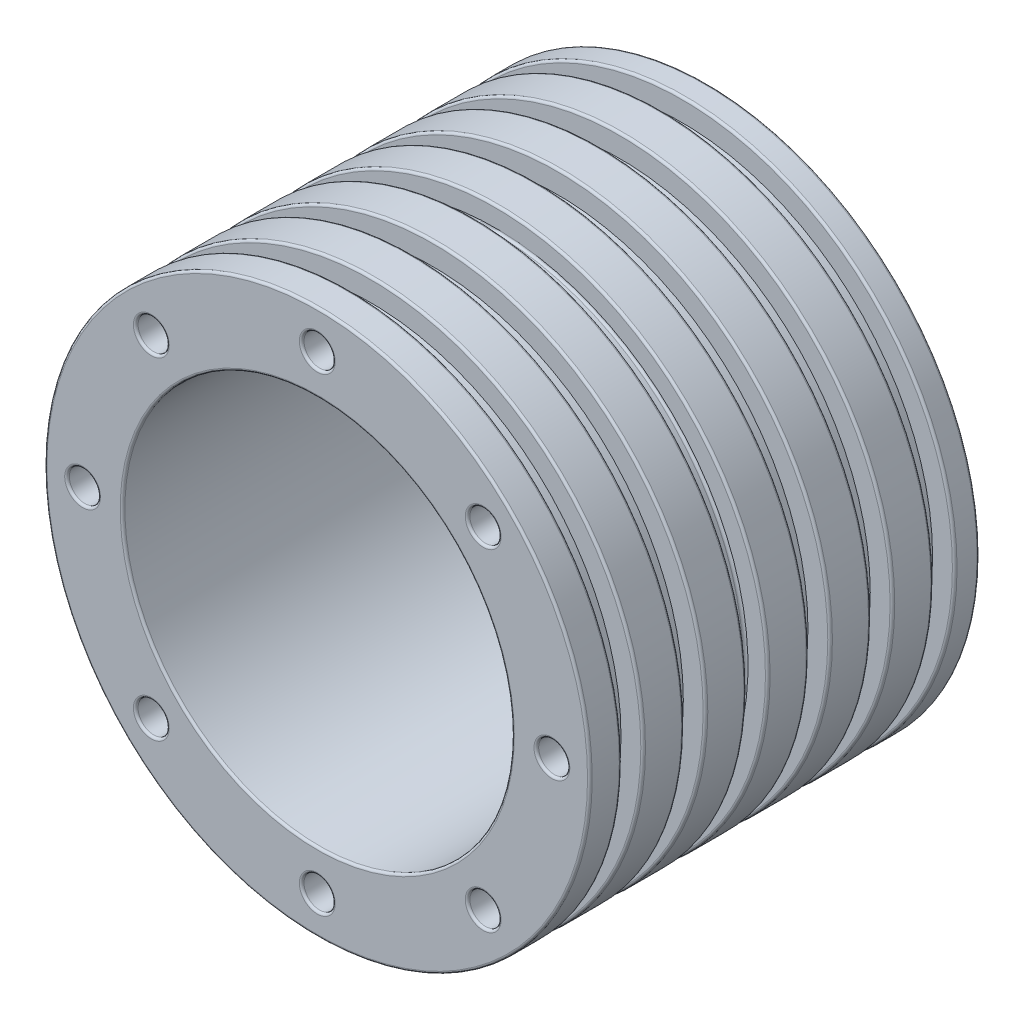
from build123d import *

# Parameters (mm, degrees)
SKETCH1_R           = 350
SKETCH1_R_2         = 250
BOSS_EXTRUDE1_DEPTH = 250
SKETCH2_W           = 27.603113623
SKETCH2_H           = 41.463524477
LPATTERN1_COUNT     = 6
LPATTERN1_PITCH     = 80
SKETCH3_R           = 20
CUT_EXTRUDE1_DEPTH  = 500
CIRPATTERN1_COUNT   = 8
FILLET1_R           = 3


with BuildPart() as part:
    # Sketch1 → Boss-Extrude1 (new, symmetric)
    with BuildSketch(Plane.XY):
        Circle(SKETCH1_R)
        Circle(SKETCH1_R_2, mode=Mode.SUBTRACT)
    extrude(amount=BOSS_EXTRUDE1_DEPTH, both=True)

    # Cut-Sweep1: sweep along a curve in space
    with BuildLine() as cut_sweep1_path:
        ThreePointArc((350, 0, 250), (247.487373415, 247.487373415, 250), (0, 350, 250))
        ThreePointArc((0, 350, 250), (-247.487373415, 247.487373415, 250), (-350, 0, 250))
        ThreePointArc((-350, 0, 250), (-247.487373415, -247.487373415, 250), (0, -350, 250))
        ThreePointArc((0, -350, 250), (247.487373415, -247.487373415, 250), (350, 0, 250))
    # Sketch2 → Cut-Sweep1 (sweep, cut)
    with BuildSketch(Plane(origin=(0, 0, 0), x_dir=(0, 0, -1), z_dir=(1, 0, 0))):
        with Locations((-195.42656015, 342.293613499)):
            Rectangle(SKETCH2_W, SKETCH2_H)
    cut_sweep1 = sweep(path=cut_sweep1_path.line, mode=Mode.SUBTRACT)

    # LPattern1: Cut-Sweep1 ×6
    with Locations(*[(0, 0, -i * LPATTERN1_PITCH) for i in range(1, LPATTERN1_COUNT)]):
        add(cut_sweep1, mode=Mode.SUBTRACT)

    # Sketch3 → Cut-Extrude1 (cut)
    with BuildSketch(Plane.XY.offset(250)):
        with Locations((0, 301.242863877)):
            Circle(SKETCH3_R)
    cut_extrude1 = extrude(amount=-CUT_EXTRUDE1_DEPTH, mode=Mode.SUBTRACT)

    # CirPattern1: Cut-Extrude1 ×8 about axis
    cirpattern1_axis = Axis((0, 0, 0), (0, 0, 1))
    for i in range(1, CIRPATTERN1_COUNT):
        add(cut_extrude1.rotate(cirpattern1_axis, i * 360 / CIRPATTERN1_COUNT), mode=Mode.SUBTRACT)

    # Fillet1
    fillet1_edges = [part.edges().sort_by_distance(p)[0] for p in [
        (-350, 0, 209.228116961),
        (-350, 0, 181.625003338),
        (-350, 0, 129.228116961),
        (-350, 0, 101.625003338),
        (-350, 0, -250),
        (-350, 0, 49.228116961),
        (-350, 0, 21.625003338),
        (0, 321.56185126, 21.625003338),
        (-350, 0, -30.771883039),
        (-350, 0, -58.374996662),
        (-350, 0, -110.771883039),
        (-350, 0, -138.374996662),
        (-350, 0, 250),
        (0, 321.56185126, -190.771883039),
        (-350, 0, -190.771883039),
        (-350, 0, -218.374996662),
        (-250, 0, -250),
        (-20, 301.242863877, -250),
        (-20, 301.242863877, 250),
        (-250, 0, 250),
        (-227.153007455, 198.868736207, 250),
        (-227.153007455, 198.868736207, -250),
        (-301.242863877, -20, 250),
        (-301.242863877, -20, -250),
        (-198.868736207, -227.153007455, 250),
        (-198.868736207, -227.153007455, -250),
        (20, -301.242863877, 250),
        (20, -301.242863877, -250),
        (227.153007455, -198.868736207, 250),
        (227.153007455, -198.868736207, -250),
        (301.242863877, 20, 250),
        (301.242863877, 20, -250),
        (198.868736207, 227.153007455, 250),
        (198.868736207, 227.153007455, -250),
    ]]
    fillet(fillet1_edges, radius=FILLET1_R)


solid = part.part
